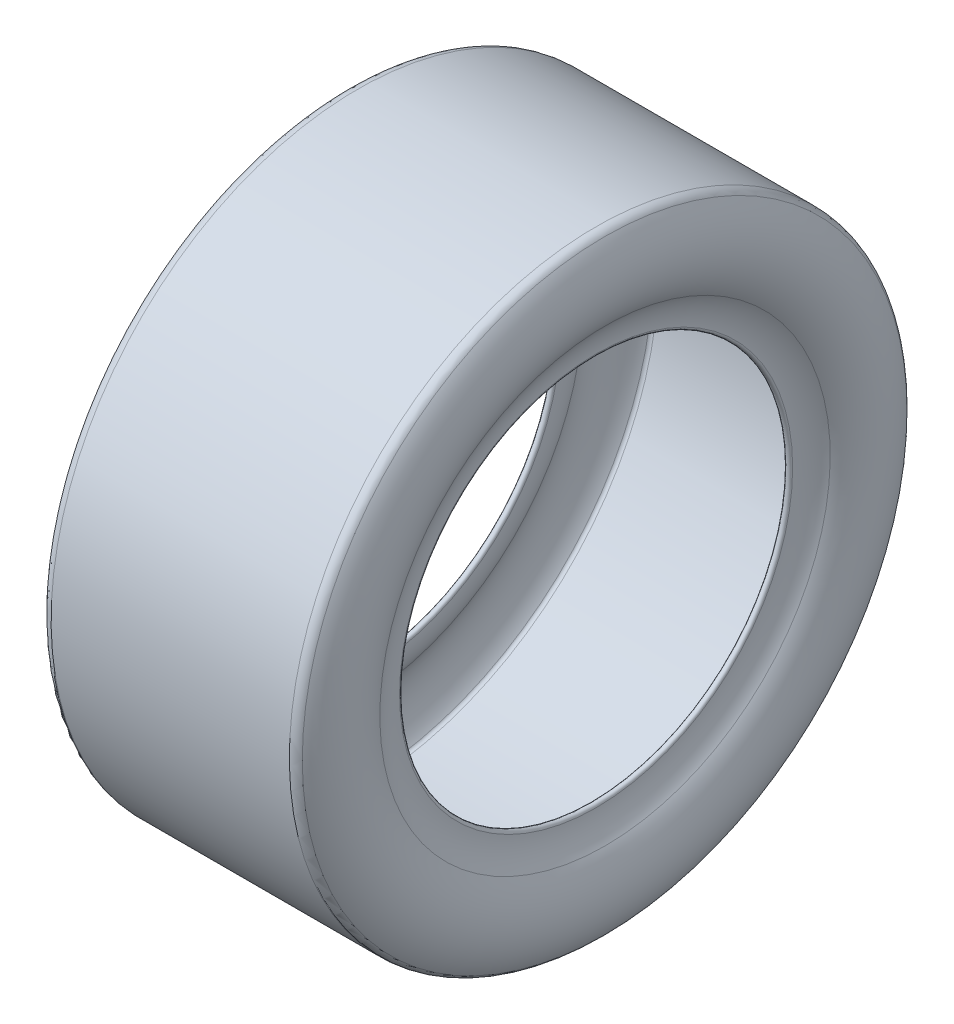
from build123d import *


with BuildPart() as part:
    # Sketch3 → Tire (revolve)
    with BuildSketch(Plane.XY):
        with BuildLine():
            Line((-101.6, 261.62), (101.6, 261.62))
            ThreePointArc((101.6, 261.62), (105.688488185, 260.623634259), (108.860167055, 257.85796373))
            ThreePointArc((108.860167055, 257.85796373), (119.379190886, 225.016179083), (109.209263361, 192.064619858))
            ThreePointArc((109.209263361, 192.064619858), (103.546361654, 180.431236689), (101.6, 167.64))
            ThreePointArc((101.6, 167.64), (99.06, 165.1), (96.52, 167.64))
            ThreePointArc((96.52, 167.64), (98.696280622, 181.942234367), (105.028127134, 194.949840794))
            ThreePointArc((105.028127134, 194.949840794), (114.299262394, 224.989225227), (104.70988307, 254.928536681))
            ThreePointArc((104.70988307, 254.928536681), (103.351298571, 256.113208037), (101.6, 256.54))
            Line((101.6, 256.54), (-101.6, 256.54))
            ThreePointArc((-101.6, 256.54), (-103.351298571, 256.113208037), (-104.70988307, 254.928536681))
            ThreePointArc((-104.70988307, 254.928536681), (-114.299262394, 224.989225227), (-105.028127134, 194.949840794))
            ThreePointArc((-105.028127134, 194.949840794), (-98.696280622, 181.942234367), (-96.52, 167.64))
            ThreePointArc((-96.52, 167.64), (-99.06, 165.1), (-101.6, 167.64))
            ThreePointArc((-101.6, 167.64), (-103.546361654, 180.431236689), (-109.209263361, 192.064619858))
            ThreePointArc((-109.209263361, 192.064619858), (-119.379190886, 225.016179083), (-108.860167055, 257.85796373))
            ThreePointArc((-108.860167055, 257.85796373), (-105.688488185, 260.623634259), (-101.6, 261.62))
        make_face()
    revolve(axis=Axis((-23.17871602, 0, 0), (1, 0, 0)))


solid = part.part
